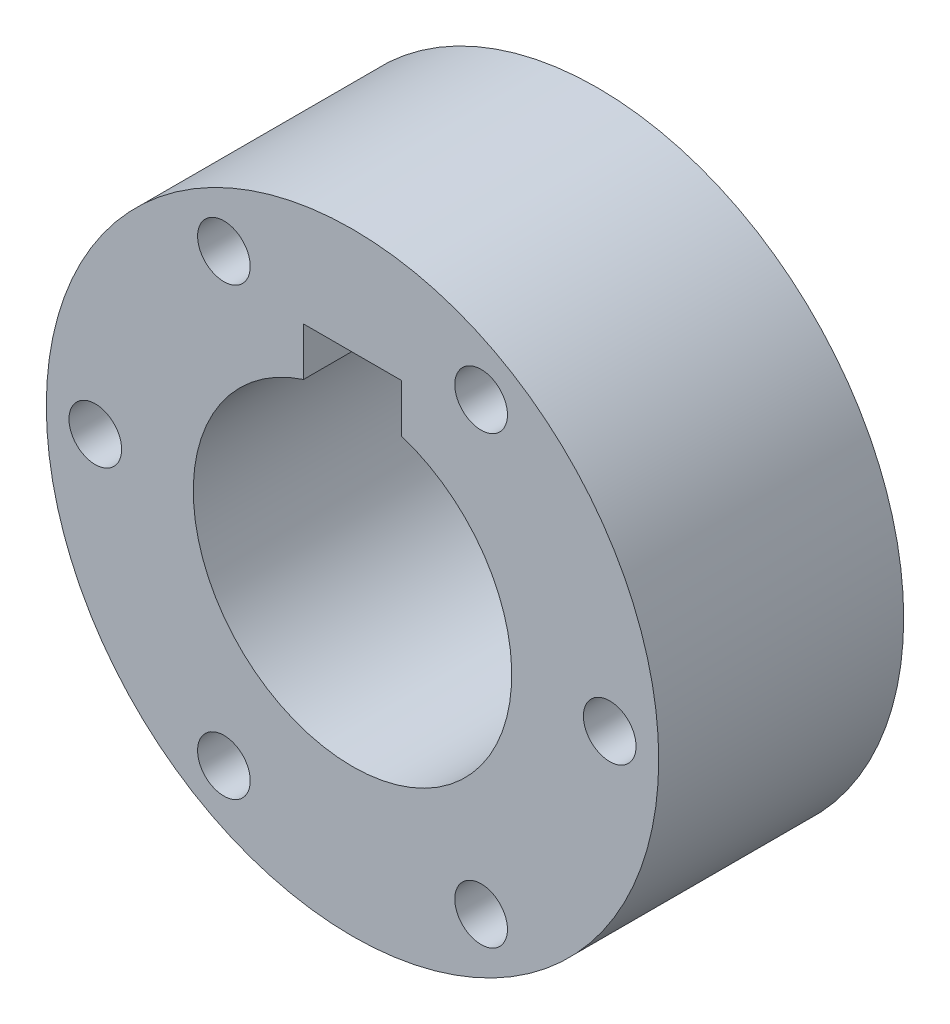
from build123d import *

# Parameters (mm, degrees)
CROQUIS1_R                   = 25
SALIENTE_EXTRUIR1_DEPTH      = 20
KEYWAY_DEPTH                 = 21
TALADRO_DE_MARGEN_PARA_M41_D = 4.3


with BuildPart() as part:
    # Croquis1 → Saliente-Extruir1 (new body)
    with BuildSketch(Plane.XY):
        Circle(CROQUIS1_R)
    extrude(amount=SALIENTE_EXTRUIR1_DEPTH)

    # KeySketch → Keyway (cut, through all)
    with BuildSketch(Plane(origin=(-0.358560603, -1.171254478, 20), x_dir=(1, 0, 0), z_dir=(0, 0, 1))):
        with BuildLine():
            Line((-3.641439397, 13.540571355), (-3.641439397, 17.471254478))
            Line((-3.641439397, 17.471254478), (4.358560603, 17.471254478))
            Line((4.358560603, 17.471254478), (4.358560603, 13.540571355))
            ThreePointArc((4.358560603, 13.540571355), (0.358560603, -11.828745522), (-3.641439397, 13.540571355))
        make_face()
    extrude(amount=-KEYWAY_DEPTH, mode=Mode.SUBTRACT)

    # Taladro de margen para M41 (through all)
    with Locations(Plane.XY.offset(20)):
        with Locations((21, 0), (10.5, -18.186533479), (-10.5, -18.186533479), (-21, 0), (-10.5, 18.186533479), (10.5, 18.186533479)):
            Hole(TALADRO_DE_MARGEN_PARA_M41_D / 2)


solid = part.part
